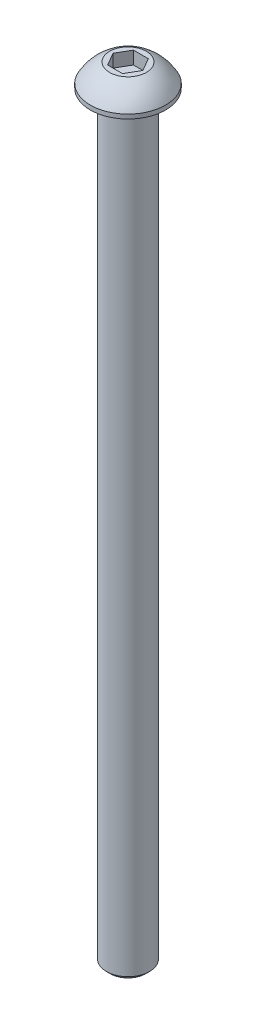
from build123d import *

# Parameters (mm, degrees)
CUT_EXTRUDE1_DEPTH = 2.38125


with BuildPart() as part:
    # Sketch1 → Base-Revolve (revolve)
    with BuildSketch(Plane.XY):
        with BuildLine():
            Line((0, -139.7), (3.263194444, -139.7))
            Line((3.263194444, -139.7), (3.96875, -138.994444444))
            Line((3.96875, -138.994444444), (3.96875, 0))
            Line((3.96875, 0), (6.9469, 0))
            Line((6.9469, 0), (6.9469, 0.7874))
            ThreePointArc((6.9469, 0.7874), (5.442852348, 2.789756108), (3.384630657, 4.2164))
            Line((3.384630657, 4.2164), (0, 4.2164))
            Line((0, 4.2164), (0, -139.7))
        make_face()
    revolve(axis=Axis((0, 69.088, 0), (0, -1, 0)))

    # Sketch2 → Cut-Extrude1 (cut)
    with BuildSketch(Plane(origin=(0, 4.2164, 0), x_dir=(-1, 0, 0), z_dir=(0, 1, 0))):
        Polygon((-2.749630657, 0), (-1.374815329, -2.38125), (1.374815329, -2.38125), (2.749630657, 0), (1.374815329, 2.38125), (-1.374815329, 2.38125), align=None)
    extrude(amount=-CUT_EXTRUDE1_DEPTH, mode=Mode.SUBTRACT)


solid = part.part
